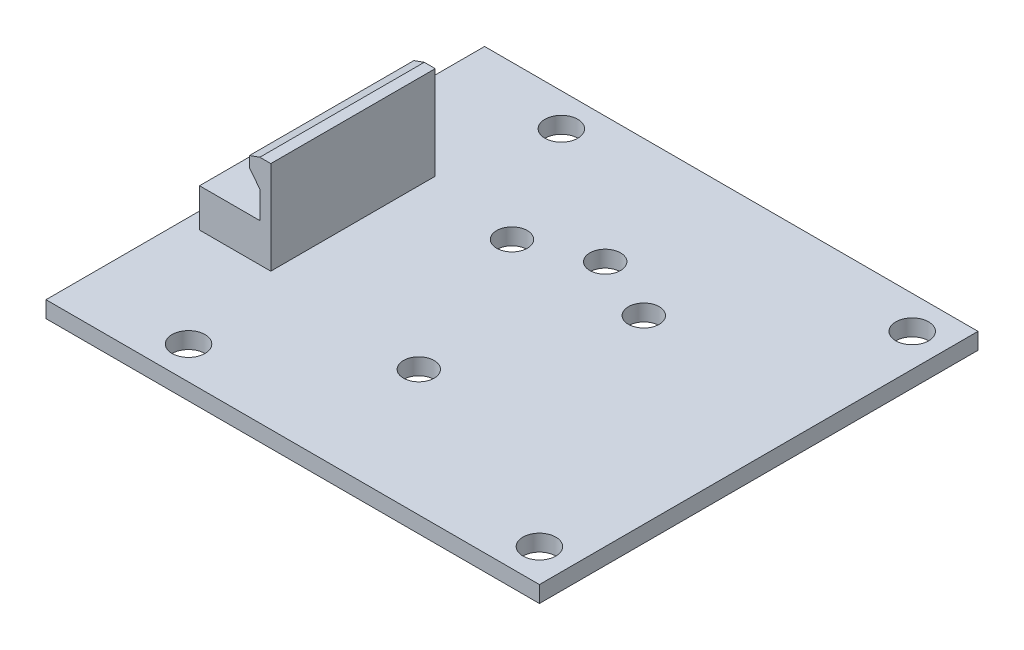
from build123d import *

# Parameters (mm, degrees)
SKETCH2_W           = 45
SKETCH2_H           = 40
BOSS_EXTRUDE2_DEPTH = 1.5
SKETCH4_R           = 1.4
CUT_EXTRUDE1_DEPTH  = 2.5
SKETCH5_W           = 6.5
SKETCH5_H           = 15
BOSS_EXTRUDE3_DEPTH = 3.5
SKETCH6_W           = 1
SKETCH6_H           = 15
BOSS_EXTRUDE4_DEPTH = 5
BOSS_EXTRUDE5_DEPTH = 15
SKETCH9_R           = 1.5
CUT_EXTRUDE2_DEPTH  = 2.5


with BuildPart() as part:
    # Sketch2 → Boss-Extrude2 (new body)
    with BuildSketch(Plane(origin=(0, 0, 0), x_dir=(1, 0, 0), z_dir=(0, 1, 0))):
        Rectangle(SKETCH2_W, SKETCH2_H)
    extrude(amount=-BOSS_EXTRUDE2_DEPTH)

    # Sketch4 → Cut-Extrude1 (cut, through all)
    with BuildSketch(Plane(origin=(0, 0, 0), x_dir=(1, 0, 0), z_dir=(0, 1, 0))):
        with Locations((0, 8.5)):
            Circle(SKETCH4_R)
        with Locations((6.01040764, 6.01040764)):
            Circle(SKETCH4_R)
        with Locations((0, -8.5)):
            Circle(SKETCH4_R)
        with Locations((-6.01040764, 6.01040764)):
            Circle(SKETCH4_R)
    extrude(amount=-CUT_EXTRUDE1_DEPTH, mode=Mode.SUBTRACT)

    # Sketch5 → Boss-Extrude3 (add)
    with BuildSketch(Plane(origin=(0, 0, 0), x_dir=(1, 0, 0), z_dir=(0, 1, 0))):
        with Locations((-17.75, 0)):
            Rectangle(SKETCH5_W, SKETCH5_H)
    extrude(amount=BOSS_EXTRUDE3_DEPTH)

    # Sketch6 → Boss-Extrude4 (add)
    with BuildSketch(Plane(origin=(0, 3.5, 0), x_dir=(1, 0, 0), z_dir=(0, 1, 0))):
        with Locations((-15, 0)):
            Rectangle(SKETCH6_W, SKETCH6_H)
    extrude(amount=BOSS_EXTRUDE4_DEPTH)

    # Sketch7 → Boss-Extrude5 (add)
    with BuildSketch(Plane.XY.offset(7.5)):
        Polygon((-15.5, 8.5), (-16.442809042, 8.166666667), (-16.442809042, 7.166666667), (-15.5, 6), align=None)
    extrude(amount=-BOSS_EXTRUDE5_DEPTH)

    # Sketch9 → Cut-Extrude2 (cut, through all)
    with BuildSketch(Plane(origin=(0, 0, 0), x_dir=(1, 0, 0), z_dir=(0, 1, 0))):
        with Locations((-12.5, 17)):
            Circle(SKETCH9_R)
        with Locations((-12.5, -17)):
            Circle(SKETCH9_R)
        with Locations((19.5, 17)):
            Circle(SKETCH9_R)
        with Locations((19.5, -17)):
            Circle(SKETCH9_R)
    extrude(amount=-CUT_EXTRUDE2_DEPTH, mode=Mode.SUBTRACT)


solid = part.part
